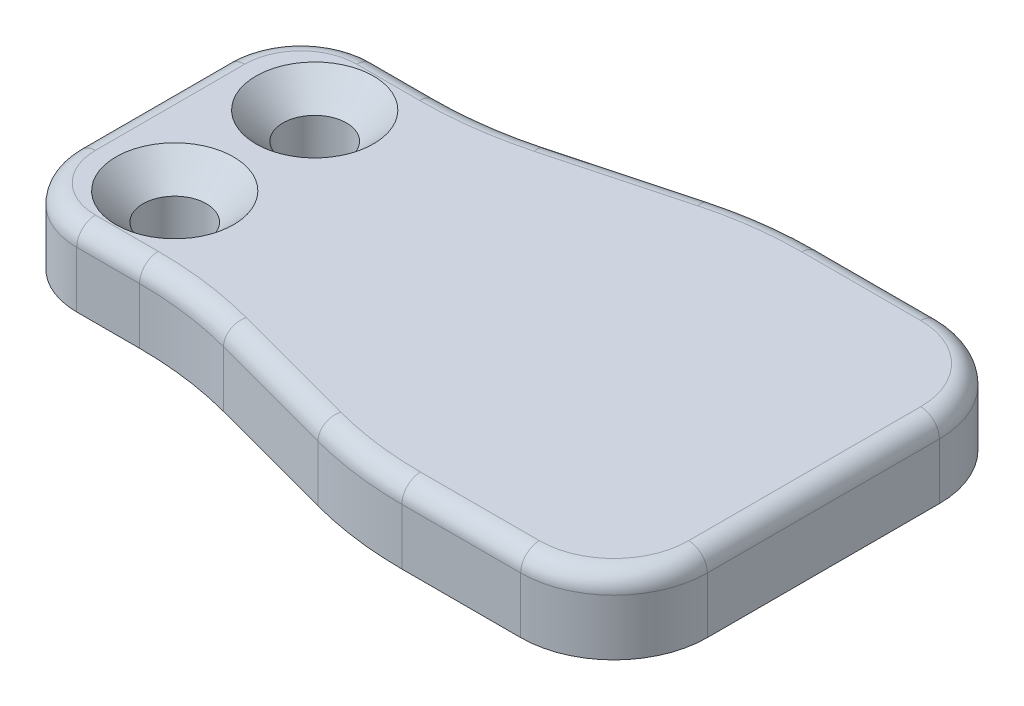
from build123d import *

# Parameters (mm, degrees)
DODANIE_WYCI_GNI_CIE3_DEPTH                      = 4
POG_BIENIE_STO_KOWE_POD_M3_RUB_Z_BEM_D           = 3.4
POG_BIENIE_STO_KOWE_POD_M3_RUB_Z_BEM_DEPTH       = 8
POG_BIENIE_STO_KOWE_POD_M3_RUB_Z_BEM_CSINK_D     = 6.3
POG_BIENIE_STO_KOWE_POD_M3_RUB_Z_BEM_CSINK_ANGLE = 90
POG_BIENIE_STO_KOWE_POD_M3_RUB_Z_BEM_TIP         = 1.021463052
ZAOKR_GLENIE2_R                                  = 4
ZAOKR_GLENIE3_R                                  = 20
ZAOKR_GLENIE4_R                                  = 5
ZAOKR_GLENIE5_R                                  = 1


with BuildPart() as part:
    # Szkic21 → Dodanie-wyciągnięcie3 (new body)
    with BuildSketch(Plane.XZ.offset(6)):
        Polygon((0, 37.975009918), (0, 29.975009918), (10, 29.975009918), (22, 26.759619609), (36, 26.759619609), (36, 37.975009918), align=None)
        Polygon((0, 45.975009918), (0, 37.975009918), (36, 37.975009918), (36, 49.190400227), (22, 49.190400227), (10, 45.975009918), align=None)
    extrude(amount=-DODANIE_WYCI_GNI_CIE3_DEPTH)

    # Pogłębienie stożkowe pod M3 Śrubę z łbem soczewkowym2
    with Locations(Plane(origin=(0, -2, 0), x_dir=(1, 0, 0), z_dir=(0, 1, 0))):
        with Locations((5, -41.725009918), (5, -34.225009918)):
            CounterSinkHole(POG_BIENIE_STO_KOWE_POD_M3_RUB_Z_BEM_D / 2, POG_BIENIE_STO_KOWE_POD_M3_RUB_Z_BEM_CSINK_D / 2, depth=POG_BIENIE_STO_KOWE_POD_M3_RUB_Z_BEM_DEPTH, counter_sink_angle=POG_BIENIE_STO_KOWE_POD_M3_RUB_Z_BEM_CSINK_ANGLE)
            with Locations((0, 0, -(POG_BIENIE_STO_KOWE_POD_M3_RUB_Z_BEM_DEPTH + POG_BIENIE_STO_KOWE_POD_M3_RUB_Z_BEM_TIP / 2))):  # 118° drill point
                Cone(0, POG_BIENIE_STO_KOWE_POD_M3_RUB_Z_BEM_D / 2, POG_BIENIE_STO_KOWE_POD_M3_RUB_Z_BEM_TIP, mode=Mode.SUBTRACT)

    # Zaokrąglenie2
    zaokr_glenie2_edges = [part.edges().sort_by_distance(p)[0] for p in [
        (0, -4, 45.975009918),
        (0, -4, 29.975009918),
    ]]
    fillet(zaokr_glenie2_edges, radius=ZAOKR_GLENIE2_R)

    # Zaokrąglenie3
    zaokr_glenie3_edges = [part.edges().sort_by_distance(p)[0] for p in [
        (22, -4, 49.190400227),
        (10, -4, 45.975009918),
        (22, -4, 26.759619609),
        (10, -4, 29.975009918),
    ]]
    fillet(zaokr_glenie3_edges, radius=ZAOKR_GLENIE3_R)

    # Zaokrąglenie4
    zaokr_glenie4_edges = [part.edges().sort_by_distance(p)[0] for p in [
        (36, -4, 49.190400227),
        (36, -4, 26.759619609),
    ]]
    fillet(zaokr_glenie4_edges, radius=ZAOKR_GLENIE4_R)

    # Zaokrąglenie5
    zaokr_glenie5_edges = [part.edges().sort_by_distance(p)[0] for p in [
        (34.535533906, -2, 28.224085703),
        (27.816524976, -2, 26.759619609),
        (22.022526107, -2, 26.930722382),
        (16, -2, 28.367314764),
        (9.977473893, -2, 29.803907146),
        (5.683475024, -2, 29.975009918),
        (1.171572875, -2, 31.146582793),
        (0, -2, 37.975009918),
        (1.171572875, -2, 44.803437043),
        (5.683475024, -2, 45.975009918),
        (9.977473893, -2, 46.146112691),
        (16, -2, 47.582705073),
        (22.022526107, -2, 49.019297455),
        (27.816524976, -2, 49.190400227),
        (34.535533906, -2, 47.725934133),
        (36, -2, 37.975009918),
    ]]
    fillet(zaokr_glenie5_edges, radius=ZAOKR_GLENIE5_R)


solid = part.part
